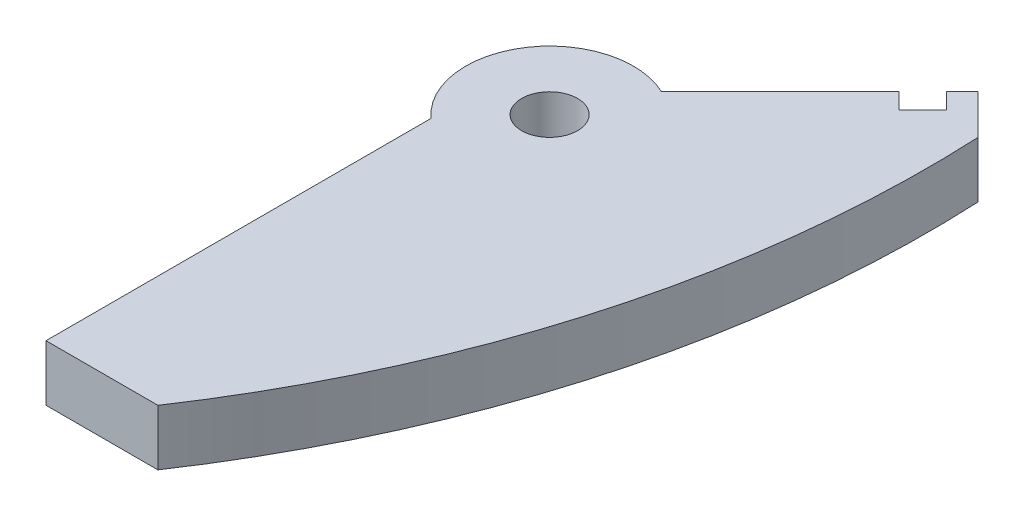
from build123d import *

# Parameters (mm, degrees)
SKETCH1_R           = 3.175
BOSS_EXTRUDE1_DEPTH = 3.175


with BuildPart() as part:
    # Sketch1 → Boss-Extrude1 (new body, symmetric)
    with BuildSketch(Plane(origin=(0, 0, 0), x_dir=(1, 0, 0), z_dir=(0, 1, 0))):
        with BuildLine():
            Line((4.10493597, 8.59506403), (17.575320151, 22.065448212))
            Line((17.575320151, 22.065448212), (19.371371376, 20.269396988))
            Line((19.371371376, 20.269396988), (22.065448212, 22.963473824))
            Line((22.065448212, 22.963473824), (20.269396988, 24.759525048))
            Line((20.269396988, 24.759525048), (22.065448212, 26.555576272))
            Line((22.065448212, 26.555576272), (26.555576272, 22.065448212))
            ThreePointArc((26.555576272, 22.065448212), (22.310576634, -15.991639638), (6.35, -50.8))
            Line((6.35, -50.8), (-6.35, -50.8))
            Line((-6.35, -50.8), (-6.35, -7.099515829))
            ThreePointArc((-6.35, -7.099515829), (-7.92717083, 5.280680604), (4.10493597, 8.59506403))
        make_face()
        Circle(SKETCH1_R, mode=Mode.SUBTRACT)
    extrude(amount=BOSS_EXTRUDE1_DEPTH, both=True)


solid = part.part
